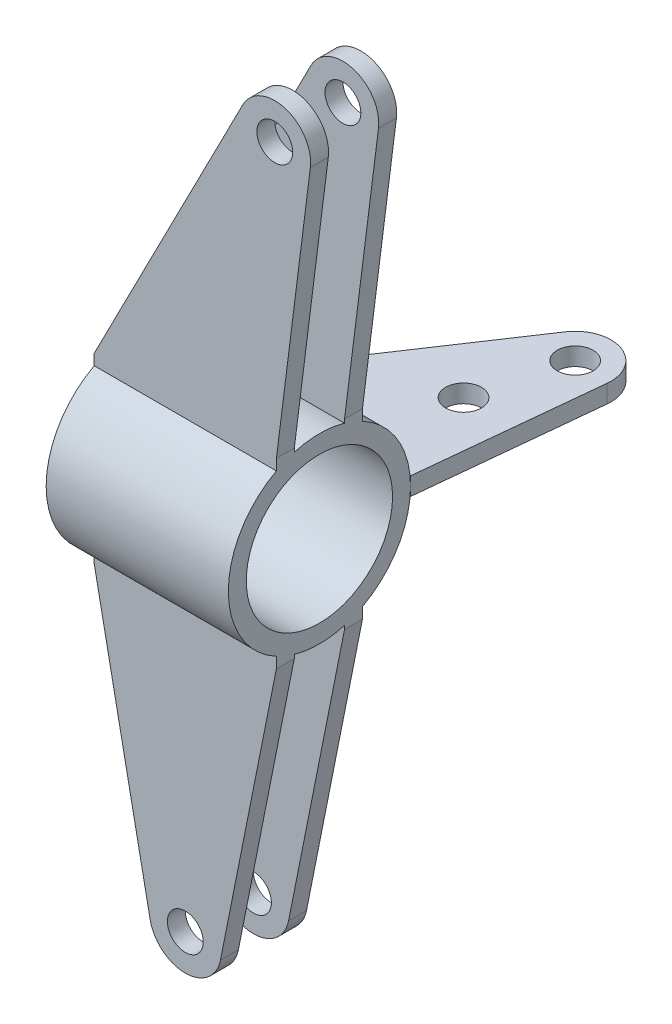
from build123d import *

# Parameters (mm, degrees)
SKETCH2_R             = 25.4
SKETCH2_R_2           = 20.4
BOSS_EXTRUDE1_DEPTH   = 25.4
BOSS_EXTRUDE2_START   = 7
SKETCH3_R             = 5
BOSS_EXTRUDE2_DEPTH   = 5
BOSS_EXTRUDE2_2_DEPTH = 5
BOSS_EXTRUDE3_START   = -7
SKETCH3_2_R           = 5
BOSS_EXTRUDE3_DEPTH   = 5
BOSS_EXTRUDE3_2_DEPTH = 5
BOSS_EXTRUDE4_DEPTH   = 25.4
SKETCH6_R             = 5
BOSS_EXTRUDE6_DEPTH   = 2.5


with BuildPart() as part:
    # Sketch2 → Boss-Extrude1 (new, symmetric)
    with BuildSketch(Plane(origin=(0, 0, 0), x_dir=(0, 0, -1), z_dir=(1, 0, 0))):
        Circle(SKETCH2_R)
        Circle(SKETCH2_R_2, mode=Mode.SUBTRACT)
    extrude(amount=BOSS_EXTRUDE1_DEPTH, both=True)



with BuildPart() as body_2:
    # Sketch3 → Boss-Extrude2 (new body)
    with BuildSketch(Plane.XY.offset(BOSS_EXTRUDE2_START)):
        with BuildLine():
            Line((-25.4, 25.4), (16.053197995, 106.166187415))
            ThreePointArc((16.053197995, 106.166187415), (27.904518621, 111.153521469), (34.870920337, 100.346276275))
            Line((34.870920337, 100.346276275), (25.4, 25.4))
            Line((25.4, 25.4), (-25.4, 25.4))
        make_face()
        with Locations((24.949822775, 101.6)):
            Circle(SKETCH3_R, mode=Mode.SUBTRACT)
    extrude(amount=BOSS_EXTRUDE2_DEPTH)


with BuildPart() as body_3:
    # Sketch3 → Boss-Extrude2 2 (new body)
    with BuildSketch(Plane.XY.offset(BOSS_EXTRUDE2_START)):
        with BuildLine():
            Line((-25.4, -25.4), (-9.806723533, -103.556571886))
            ThreePointArc((-9.806723533, -103.556571886), (0, -111.6), (9.806723533, -103.556571886))
            Line((9.806723533, -103.556571886), (25.4, -25.4))
            Line((25.4, -25.4), (-25.4, -25.4))
        make_face()
        with Locations((0, -101.6)):
            Circle(SKETCH3_R, mode=Mode.SUBTRACT)
    extrude(amount=BOSS_EXTRUDE2_2_DEPTH)


with BuildPart() as body_4:
    # Sketch3_2 → Boss-Extrude3 (new body)
    with BuildSketch(Plane.XY.offset(BOSS_EXTRUDE3_START)):
        with BuildLine():
            Line((-25.4, 25.4), (16.053197995, 106.166187415))
            ThreePointArc((16.053197995, 106.166187415), (27.904518621, 111.153521469), (34.870920337, 100.346276275))
            Line((34.870920337, 100.346276275), (25.4, 25.4))
            Line((25.4, 25.4), (-25.4, 25.4))
        make_face()
        with Locations((24.949822775, 101.6)):
            Circle(SKETCH3_2_R, mode=Mode.SUBTRACT)
    extrude(amount=-BOSS_EXTRUDE3_DEPTH)


with BuildPart() as body_5:
    # Sketch3_2 → Boss-Extrude3 2 (new body)
    with BuildSketch(Plane.XY.offset(BOSS_EXTRUDE3_START)):
        with BuildLine():
            Line((-25.4, -25.4), (-9.806723533, -103.556571886))
            ThreePointArc((-9.806723533, -103.556571886), (0, -111.6), (9.806723533, -103.556571886))
            Line((9.806723533, -103.556571886), (25.4, -25.4))
            Line((25.4, -25.4), (-25.4, -25.4))
        make_face()
        with Locations((0, -101.6)):
            Circle(SKETCH3_2_R, mode=Mode.SUBTRACT)
    extrude(amount=-BOSS_EXTRUDE3_2_DEPTH)


with BuildPart() as part_1:
    add(part.part)

    add(body_2.part)  # Boss-Extrude4 merges body 2

    add(body_3.part)  # Boss-Extrude4 merges body 3

    add(body_4.part)  # Boss-Extrude4 merges body 4

    add(body_5.part)  # Boss-Extrude4 merges body 5
    # Sketch4 → Boss-Extrude4 (add, symmetric)
    with BuildSketch(Plane(origin=(0, 0, 0), x_dir=(0, 0, -1), z_dir=(1, 0, 0))):
        with BuildLine():
            Line((-12, -25.4), (-7, -25.4))
            Line((-7, -25.4), (-7, -24.416387939))
            ThreePointArc((-7, -24.416387939), (-9.554057075, -23.534655158), (-12, -22.386603137))
            Line((-12, -22.386603137), (-12, -25.4))
        make_face()
        with BuildLine():
            Line((12, -25.4), (7, -25.4))
            Line((7, -25.4), (7, -24.416387939))
            ThreePointArc((7, -24.416387939), (9.554057075, -23.534655158), (12, -22.386603137))
            Line((12, -22.386603137), (12, -25.4))
        make_face()
        with BuildLine():
            Line((12, 25.4), (7, 25.4))
            Line((7, 25.4), (7, 24.416387939))
            ThreePointArc((7, 24.416387939), (9.554057075, 23.534655158), (12, 22.386603137))
            Line((12, 22.386603137), (12, 25.4))
        make_face()
        with BuildLine():
            Line((-12, 25.4), (-7, 25.4))
            Line((-7, 25.4), (-7, 24.416387939))
            ThreePointArc((-7, 24.416387939), (-9.554057075, 23.534655158), (-12, 22.386603137))
            Line((-12, 22.386603137), (-12, 25.4))
        make_face()
    extrude(amount=BOSS_EXTRUDE4_DEPTH, both=True)


with BuildPart() as body_2_2:
    # Sketch6 → Boss-Extrude6 (new, symmetric)
    with BuildSketch(Plane(origin=(0, 0, 0), x_dir=(1, 0, 0), z_dir=(0, 1, 0))):
        with BuildLine():
            Line((-25.4, 25.4), (12.199244226, 81.750309743))
            ThreePointArc((12.199244226, 81.750309743), (23.898598023, 85.611081427), (30.466168735, 75.18767257))
            Line((30.466168735, 75.18767257), (25.4, 25.4))
            Line((25.4, 25.4), (-25.4, 25.4))
        make_face()
        with Locations((20.517541032, 76.2)):
            Circle(SKETCH6_R, mode=Mode.SUBTRACT)
        with Locations((13.913567634, 51.673533981)):
            Circle(SKETCH6_R, mode=Mode.SUBTRACT)
    extrude(amount=BOSS_EXTRUDE6_DEPTH, both=True)


solid = Compound([part_1.part, body_2_2.part])
